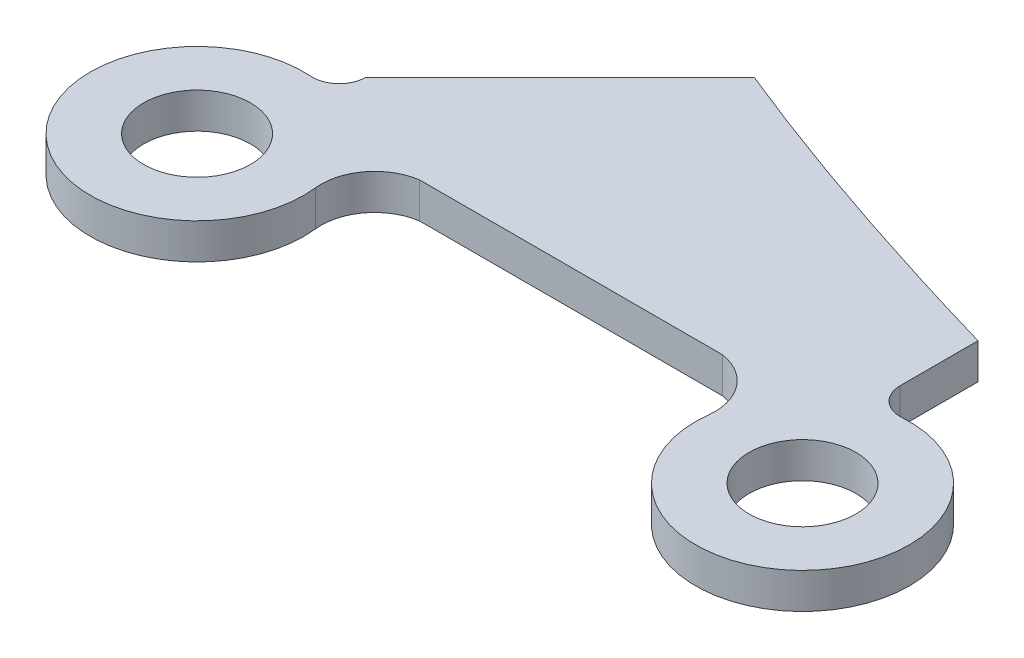
from build123d import *

# Parameters (mm, degrees)
SZKIC1_R                    = 3
DODANIE_WYCI_GNI_CIE1_DEPTH = 2


with BuildPart() as part:
    # Szkic1 → Dodanie-wyciągnięcie1 (new body)
    with BuildSketch(Plane.XZ.offset(334.439810961)):
        with BuildLine():
            ThreePointArc((1003.4, 432.296579888), (1004.524695077, 431.895362049), (1005, 430.799916934))
            Line((1005, 430.799916934), (1015.903797979, 419.896118954))
            add(Edge.make_bspline(
                [(1015.903797979, 419.896118954), (1021.185746723, 422.066519939), (1027.589044834, 424.271723988), (1035, 426.42724062)],
                knots=[0.141934854, 0.141934854, 0.141934854, 0.141934854, 0.193423322, 0.193423322, 0.193423322, 0.193423322], degree=3, weights=[0.593424606, 0.563749359, 0.541143612, 0.525607364]))
            Line((1035, 426.42724062), (1035, 430.799916934))
            ThreePointArc((1035, 430.799916934), (1035.475304923, 431.895362049), (1036.6, 432.296579888))
            ThreePointArc((1036.6, 432.296579888), (1041.13903563, 442.62700703), (1031.039616452, 437.59488008))
            ThreePointArc((1031.039616452, 437.59488008), (1030.440005619, 435.425099056), (1028.5, 434.283231707))
            Line((1028.5, 434.283231707), (1011.5, 434.283231707))
            ThreePointArc((1011.5, 434.283231707), (1009.559994381, 435.425099056), (1008.960383548, 437.59488008))
            ThreePointArc((1008.960383548, 437.59488008), (998.86096437, 442.62700703), (1003.4, 432.296579888))
        make_face()
        with Locations((1003, 438.283231707)):
            Circle(SZKIC1_R, mode=Mode.SUBTRACT)
        with Locations((1037, 438.283231707)):
            Circle(SZKIC1_R, mode=Mode.SUBTRACT)
    extrude(amount=DODANIE_WYCI_GNI_CIE1_DEPTH)


solid = part.part
